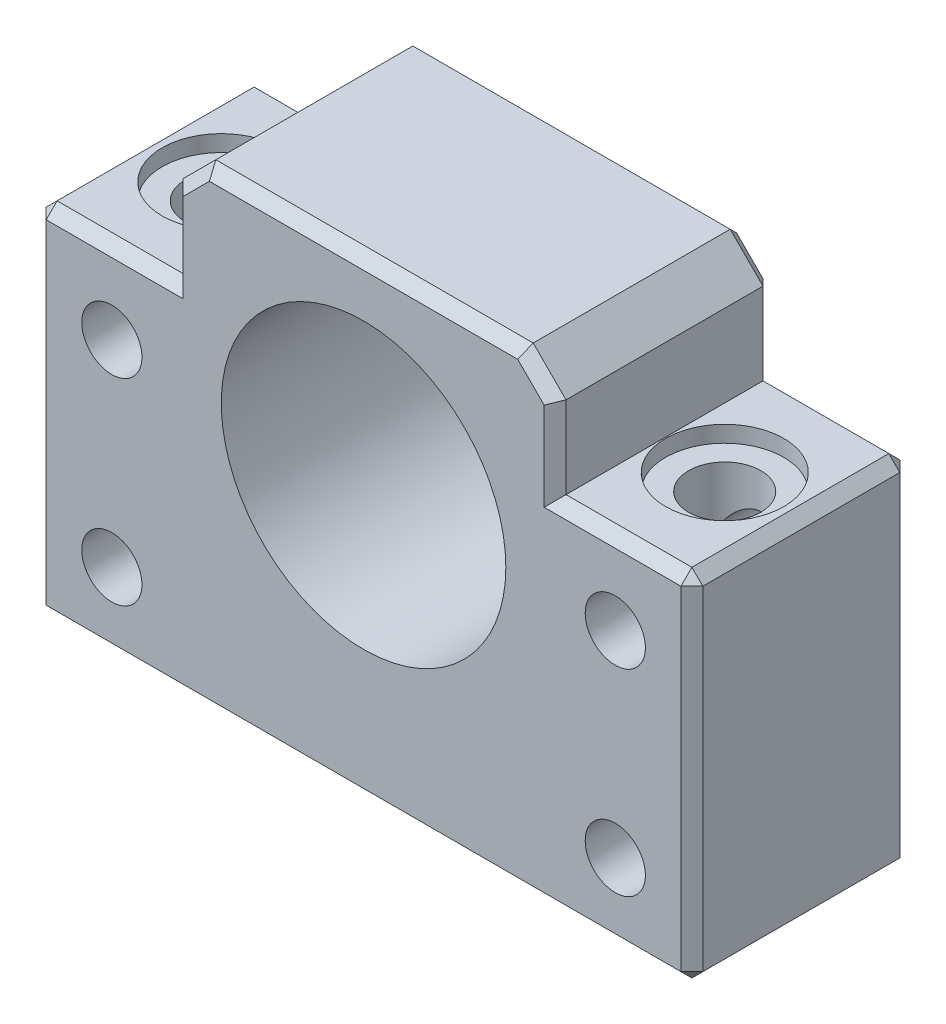
from build123d import *

# Parameters (mm, degrees)
ESBO_O1_R                = 13
RESSALTO_EXTRUS_O1_DEPTH = 20
ESBO_O4_R                = 3.3
CORTE_EXTRUS_O1_DEPTH    = 33.5
CHANFRO1_SIZE            = 3
CHANFRO3_SIZE            = 1
ESBO_O5_R                = 5.4
CORTE_EXTRUS_O2_DEPTH    = 1.5
ESBO_O6_R                = 2.75
CORTE_EXTRUS_O3_DEPTH    = 21


with BuildPart() as part:
    # Esboço1 → Ressalto-extrusão1 (new body)
    with BuildSketch(Plane.XY):
        Polygon((-30, -25), (-30, 7.5), (-17.5, 7.5), (-17.5, 18), (17.5, 18), (17.5, 7.5), (30, 7.5), (30, -25), align=None)
        Circle(ESBO_O1_R, mode=Mode.SUBTRACT)
    extrude(amount=RESSALTO_EXTRUS_O1_DEPTH)

    # Esboço4 → Corte-extrusão1 (cut, through all)
    with BuildSketch(Plane(origin=(0, 7.5, 0), x_dir=(1, 0, 0), z_dir=(0, 1, 0))):
        with Locations((-23, -10)):
            Circle(ESBO_O4_R)
        with Locations((23, -10)):
            Circle(ESBO_O4_R)
    extrude(amount=-CORTE_EXTRUS_O1_DEPTH, mode=Mode.SUBTRACT)

    # Chanfro1
    chanfro1_edges = [part.edges().sort_by_distance(p)[0] for p in [
        (-17.5, 18, 10),
        (17.5, 18, 10),
    ]]
    chamfer(chanfro1_edges, length=CHANFRO1_SIZE)

    # Chanfro3
    chanfro3_edges = [part.edges().sort_by_distance(p)[0] for p in [
        (23.75, 7.5, 20),
        (30, -8.75, 0),
        (0, -25, 0),
        (17.5, 11.25, 20),
        (-30, -25, 10),
        (-30, 7.5, 10),
        (30, 7.5, 10),
        (30, -25, 10),
        (-23.75, 7.5, 20),
        (-30, -8.75, 20),
        (0, 18, 0),
        (0, 18, 20),
        (-17.5, 11.25, 0),
        (-16, 16.5, 0),
        (0, -25, 20),
        (16, 16.5, 0),
        (-17.5, 11.25, 20),
        (-16, 16.5, 20),
        (16, 16.5, 20),
        (30, -8.75, 20),
        (-30, -8.75, 0),
        (-23.75, 7.5, 0),
        (17.5, 11.25, 0),
        (23.75, 7.5, 0),
    ]]
    chamfer(chanfro3_edges, length=CHANFRO3_SIZE)

    # Esboço5 → Corte-extrusão2 (cut)
    with BuildSketch(Plane(origin=(0, 7.5, 0), x_dir=(1, 0, 0), z_dir=(0, 1, 0))):
        with Locations((23, -10)):
            Circle(ESBO_O5_R)
        with Locations((-23, -10)):
            Circle(ESBO_O5_R)
    extrude(amount=-CORTE_EXTRUS_O2_DEPTH, mode=Mode.SUBTRACT)

    # Esboço6 → Corte-extrusão3 (cut, through all)
    with BuildSketch(Plane(origin=(0, 0, 0), x_dir=(-1, 0, 0), z_dir=(0, 0, -1))):
        with Locations((-23, 0)):
            Circle(ESBO_O6_R)
        with Locations((-23, -18)):
            Circle(ESBO_O6_R)
        with Locations((23, 0)):
            Circle(ESBO_O6_R)
        with Locations((23, -18)):
            Circle(ESBO_O6_R)
    extrude(amount=-CORTE_EXTRUS_O3_DEPTH, mode=Mode.SUBTRACT)


solid = part.part
